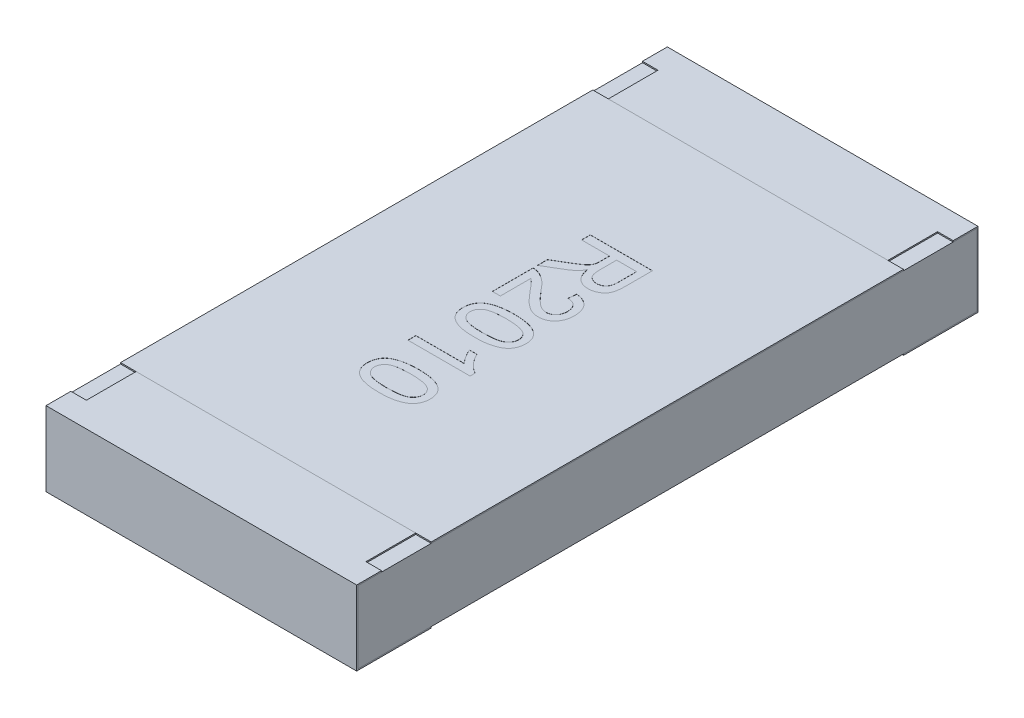
from build123d import *

# Parameters (mm, degrees)
BOSS_EXTRUDE2_DEPTH   = 1.25
BOSS_EXTRUDE2_2_DEPTH = 1.25
BOSS_EXTRUDE3_START   = -1.25
SKETCH5_W             = 4.98
SKETCH5_H             = 0.58
BOSS_EXTRUDE3_DEPTH   = 2.5
SKETCH6_W             = 0.125
SKETCH6_H             = 0.4
CUT_EXTRUDE1_DEPTH    = 0.01
SKETCH7_W             = 2.5
SKETCH7_H             = 3.8
BOSS_EXTRUDE4_DEPTH   = 0.01
TEXT2010_DEPTH        = 0.001


with BuildPart() as part:
    # Sketch4 → Boss-Extrude2 (new body, symmetric)
    with BuildSketch(Plane(origin=(0, 0, 0), x_dir=(0, 0, -1), z_dir=(1, 0, 0))):
        Polygon((-2.5, 0.3), (-2.5, -0.3), (-1.9, -0.3), (-1.9, -0.29), (-2.49, -0.29), (-2.49, 0.29), (-1.9, 0.29), (-1.9, 0.3), align=None)
    extrude(amount=BOSS_EXTRUDE2_DEPTH, both=True)


with BuildPart() as body_2:
    # Sketch4 → Boss-Extrude2 2 (new body, symmetric)
    with BuildSketch(Plane(origin=(0, 0, 0), x_dir=(0, 0, -1), z_dir=(1, 0, 0))):
        Polygon((1.9, 0.3), (2.5, 0.3), (2.5, -0.3), (1.9, -0.3), (1.9, -0.29), (2.49, -0.29), (2.49, 0.29), (1.9, 0.29), align=None)
    extrude(amount=BOSS_EXTRUDE2_2_DEPTH, both=True)


with BuildPart() as body_3:
    # Sketch5 → Boss-Extrude3 (new body)
    with BuildSketch(Plane(origin=(0, 0, 0), x_dir=(0, 0, -1), z_dir=(1, 0, 0)).offset(BOSS_EXTRUDE3_START)):
        Rectangle(SKETCH5_W, SKETCH5_H)
    extrude(amount=BOSS_EXTRUDE3_DEPTH)


with BuildPart() as cut_extrude1_tool:
    # Sketch6 → Cut-Extrude1 (new body)
    with BuildSketch(Plane(origin=(0, 0.3, 0), x_dir=(1, 0, 0), z_dir=(0, 1, 0))):
        with Locations((-1.1875, 2.1)):
            Rectangle(SKETCH6_W, SKETCH6_H)
        with Locations((1.1875, 2.1)):
            Rectangle(SKETCH6_W, SKETCH6_H)
        with Locations((1.1875, -2.1)):
            Rectangle(SKETCH6_W, SKETCH6_H)
        with Locations((-1.1875, -2.1)):
            Rectangle(SKETCH6_W, SKETCH6_H)
    extrude(amount=-CUT_EXTRUDE1_DEPTH)


with BuildPart() as part_1:
    add(part.part)

    # Cut-Extrude1: cut by cut_extrude1_tool
    add(cut_extrude1_tool.part, mode=Mode.SUBTRACT)


with BuildPart() as body_2_1:
    add(body_2.part)

    # Cut-Extrude1: cut by cut_extrude1_tool
    add(cut_extrude1_tool.part, mode=Mode.SUBTRACT)


with BuildPart() as body_4:
    # Sketch7 → Boss-Extrude4 (new body)
    with BuildSketch(Plane(origin=(0, 0.29, 0), x_dir=(1, 0, 0), z_dir=(0, 1, 0))):
        Rectangle(SKETCH7_W, SKETCH7_H)
    extrude(amount=BOSS_EXTRUDE4_DEPTH)

    # Sketch15 → TEXT2010 (cut)
    with BuildSketch(Plane(origin=(0, 0.3, 0), x_dir=(1, 0, 0), z_dir=(0, 1, 0))):
        with BuildLine():
            Line((-0.25, 0.880488889), (0.25, 0.880488889))
            Line((0.25, 0.880488889), (0.25, 0.663541774))
            add(Edge.make_bspline(
                [(0.25, 0.663541774), (0.249960163, 0.658433309), (0.249883063, 0.648546474), (0.249332125, 0.634208918), (0.248161656, 0.620857867), (0.246854386, 0.608409178), (0.244924176, 0.596884152), (0.242659692, 0.586277296), (0.239983333, 0.576629293), (0.236819773, 0.56786672), (0.233241826, 0.559736335), (0.228824875, 0.552202105), (0.223992823, 0.544941118), (0.218269952, 0.538240611), (0.212116317, 0.531807283), (0.205227709, 0.525860975), (0.197701412, 0.520372665), (0.18694151, 0.513600582), (0.17253828, 0.506474807), (0.154200832, 0.500392976), (0.134978762, 0.496504557), (0.121846978, 0.496085912), (0.115184295, 0.495873504)],
                knots=[0, 0, 0, 0, 1.5326e-05, 2.9661e-05, 4.3028e-05, 5.5527e-05, 6.7202e-05, 7.8066e-05, 8.8054e-05, 9.721e-05, 0.000105997, 0.000114656, 0.000123379, 0.000132125, 0.00014105, 0.000150068, 0.000159383, 0.00016897, 0.000188187, 0.000207412, 0.0002268, 0.000246768, 0.000246768, 0.000246768, 0.000246768], degree=3))
            add(Edge.make_bspline(
                [(0.115184295, 0.495873504), (0.110907215, 0.495971346), (0.10245969, 0.496164591), (0.090039553, 0.497644844), (0.078172662, 0.500323298), (0.066754852, 0.503757703), (0.055948764, 0.508459046), (0.045530439, 0.513902893), (0.035798164, 0.520656429), (0.026427897, 0.5281976), (0.017837878, 0.536964729), (0.00991265, 0.546723949), (0.003065461, 0.557720878), (-0.003087965, 0.569753154), (-0.008472636, 0.582842612), (-0.013000013, 0.597076292), (-0.016544481, 0.612403796), (-0.01831997, 0.623033042), (-0.019230769, 0.628485684)],
                knots=[0, 0, 0, 0, 1.283e-05, 2.5341e-05, 3.7443e-05, 4.9292e-05, 6.1049e-05, 7.2745e-05, 8.4496e-05, 9.6525e-05, 0.000108778, 0.000121245, 0.000134166, 0.00014756, 0.000161752, 0.000176576, 0.00019232, 0.000208902, 0.000208902, 0.000208902, 0.000208902], degree=3))
            add(Edge.make_bspline(
                [(-0.019230769, 0.628485684), (-0.021256287, 0.624455315), (-0.025089867, 0.616827269), (-0.03124439, 0.606305694), (-0.037334993, 0.597270614), (-0.041788652, 0.592059201), (-0.043870192, 0.589623504)],
                knots=[0, 0, 0, 0, 1.3529e-05, 2.5605e-05, 3.6551e-05, 4.6157e-05, 4.6157e-05, 4.6157e-05, 4.6157e-05], degree=3))
            add(Edge.make_bspline(
                [(-0.043870192, 0.589623504), (-0.048494022, 0.584892173), (-0.057976735, 0.575188991), (-0.074278364, 0.561947731), (-0.09220549, 0.548845663), (-0.105269317, 0.540979455), (-0.111979167, 0.536939209)],
                knots=[0, 0, 0, 0, 1.9831e-05, 4.0671e-05, 6.291e-05, 8.6395e-05, 8.6395e-05, 8.6395e-05, 8.6395e-05], degree=3))
            Line((-0.111979167, 0.536939209), (-0.25, 0.454907959))
            Line((-0.25, 0.454907959), (-0.25, 0.535737286))
            Line((-0.25, 0.535737286), (-0.14443109, 0.598036966))
            add(Edge.make_bspline(
                [(-0.14443109, 0.598036966), (-0.14072714, 0.600277042), (-0.133549493, 0.604617941), (-0.123065864, 0.610886704), (-0.113417718, 0.617038577), (-0.104312641, 0.622725698), (-0.095987375, 0.628252275), (-0.088193556, 0.633307958), (-0.081239279, 0.638281723), (-0.072863649, 0.644066276), (-0.063747422, 0.651040393), (-0.054441051, 0.659233793), (-0.046842147, 0.666836377), (-0.039501217, 0.676348247), (-0.032660963, 0.688151184), (-0.029482057, 0.698163079), (-0.027944712, 0.703004915)],
                knots=[0, 0, 0, 0, 1.2986e-05, 2.5165e-05, 3.6642e-05, 4.7312e-05, 5.7369e-05, 6.6619e-05, 7.5178e-05, 8.3014e-05, 9.7157e-05, 0.000109576, 0.000120201, 0.000129337, 0.000145574, 0.000160781, 0.000160781, 0.000160781, 0.000160781], degree=3))
            add(Edge.make_bspline(
                [(-0.027944712, 0.703004915), (-0.027578209, 0.705037271), (-0.026741472, 0.7096772), (-0.026194997, 0.717555789), (-0.025614988, 0.727101666), (-0.025631888, 0.734019726), (-0.025641026, 0.737760524)],
                knots=[0, 0, 0, 0, 6.191e-06, 1.4135e-05, 2.3663e-05, 3.4882e-05, 3.4882e-05, 3.4882e-05, 3.4882e-05], degree=3))
            Line((-0.025641026, 0.737760524), (-0.025641026, 0.809976068))
            Line((-0.025641026, 0.809976068), (-0.25, 0.809976068))
            Line((-0.25, 0.809976068), (-0.25, 0.880488889))
        make_face()
        with BuildLine():
            Line((0.032051282, 0.809976068), (0.032051282, 0.676061806))
            add(Edge.make_bspline(
                [(0.032051282, 0.676061806), (0.032156765, 0.669346925), (0.032353956, 0.656794087), (0.034025946, 0.639239632), (0.036712066, 0.624252137), (0.0405672, 0.611551859), (0.045943674, 0.600887524), (0.052623746, 0.591725856), (0.060751598, 0.583931851), (0.07009756, 0.577562003), (0.080294979, 0.572544951), (0.091082454, 0.569120007), (0.102226625, 0.56673387), (0.10982965, 0.566503199), (0.113681891, 0.566386325)],
                knots=[0, 0, 0, 0, 2.0141e-05, 3.7652e-05, 5.2837e-05, 6.5761e-05, 7.7318e-05, 8.8497e-05, 9.9618e-05, 0.000110925, 0.000122303, 0.000133579, 0.000144815, 0.000156355, 0.000156355, 0.000156355, 0.000156355], degree=3))
            add(Edge.make_bspline(
                [(0.113681891, 0.566386325), (0.116488464, 0.566479389), (0.121985715, 0.566661673), (0.130054155, 0.567617268), (0.137721037, 0.569475173), (0.14502689, 0.571928531), (0.151918204, 0.575206716), (0.158448379, 0.579101065), (0.164581222, 0.583748226), (0.170335414, 0.589071281), (0.175571167, 0.595183117), (0.180088486, 0.602164269), (0.183927233, 0.609959679), (0.186973919, 0.618578408), (0.189410772, 0.627993304), (0.191031932, 0.638257965), (0.192204997, 0.649325448), (0.192272821, 0.656994573), (0.192307692, 0.660937607)],
                knots=[0, 0, 0, 0, 8.423e-06, 1.6498e-05, 2.4321e-05, 3.205e-05, 3.9577e-05, 4.7169e-05, 5.4822e-05, 6.2617e-05, 7.0646e-05, 7.8897e-05, 8.7497e-05, 9.6653e-05, 0.000106273, 0.000116631, 0.000127803, 0.000139626, 0.000139626, 0.000139626, 0.000139626], degree=3))
            Line((0.192307692, 0.660937607), (0.192307692, 0.809976068))
            Line((0.192307692, 0.809976068), (0.032051282, 0.809976068))
        make_face(mode=Mode.SUBTRACT)
        with BuildLine():
            Line((-0.185897436, 0.09202735), (-0.25, 0.09202735))
            Line((-0.25, 0.09202735), (-0.25, 0.418950427))
            add(Edge.make_bspline(
                [(-0.25, 0.418950427), (-0.246190204, 0.41895712), (-0.238583383, 0.418970484), (-0.227333376, 0.417683287), (-0.21623261, 0.415667279), (-0.209114131, 0.41338778), (-0.205528846, 0.41223969)],
                knots=[0, 0, 0, 0, 1.142e-05, 2.2802e-05, 3.392e-05, 4.5202e-05, 4.5202e-05, 4.5202e-05, 4.5202e-05], degree=3))
            add(Edge.make_bspline(
                [(-0.205528846, 0.41223969), (-0.199672194, 0.410116329), (-0.187747085, 0.405792817), (-0.170501435, 0.397066827), (-0.153461868, 0.386632593), (-0.139489569, 0.376646806), (-0.128408004, 0.367449883), (-0.11963342, 0.359865787), (-0.110764129, 0.351322457), (-0.101641984, 0.341975633), (-0.092266458, 0.331882039), (-0.082593861, 0.321042069), (-0.07280804, 0.309323603), (-0.066321448, 0.301143058), (-0.063000801, 0.296955235)],
                knots=[0, 0, 0, 0, 1.8675e-05, 3.8026e-05, 5.7849e-05, 7.8586e-05, 8.9474e-05, 0.000101045, 0.000113371, 0.000126404, 0.000140223, 0.000154696, 0.000169983, 0.000186016, 0.000186016, 0.000186016, 0.000186016], degree=3))
            add(Edge.make_bspline(
                [(-0.063000801, 0.296955235), (-0.057585784, 0.290521682), (-0.047158825, 0.278133468), (-0.031686185, 0.260639368), (-0.017318962, 0.244661355), (-0.003805341, 0.230453862), (0.008723604, 0.217900685), (0.020239487, 0.206972349), (0.03070637, 0.197574824), (0.040503108, 0.189822835), (0.049753955, 0.183282244), (0.058777584, 0.177739671), (0.06773162, 0.173120672), (0.076587728, 0.169273663), (0.085383783, 0.166231007), (0.094145409, 0.164157003), (0.102785672, 0.162750486), (0.108534999, 0.162609763), (0.111378205, 0.162540171)],
                knots=[0, 0, 0, 0, 2.5226e-05, 4.8575e-05, 7.0061e-05, 8.9685e-05, 0.000107391, 0.000123262, 0.00013731, 0.000149574, 0.000160717, 0.000171282, 0.000181316, 0.000190917, 0.000200229, 0.000209193, 0.000217905, 0.000226428, 0.000226428, 0.000226428, 0.000226428], degree=3))
            add(Edge.make_bspline(
                [(0.111378205, 0.162540171), (0.114188238, 0.162609771), (0.119701369, 0.162746322), (0.127769802, 0.164041916), (0.135539896, 0.165845486), (0.14287177, 0.16876131), (0.149982559, 0.172232015), (0.156647535, 0.176684045), (0.163032944, 0.181834084), (0.168969907, 0.187730611), (0.17454131, 0.194170361), (0.179166687, 0.201368281), (0.183368098, 0.208867469), (0.186646742, 0.216915779), (0.189173495, 0.225441527), (0.190933763, 0.234431042), (0.192071797, 0.243908323), (0.192227868, 0.250377362), (0.192307692, 0.253686004)],
                knots=[0, 0, 0, 0, 8.423e-06, 1.6525e-05, 2.4469e-05, 3.23e-05, 4.0139e-05, 4.8167e-05, 5.6286e-05, 6.4714e-05, 7.3243e-05, 8.1771e-05, 9.0332e-05, 9.9e-05, 0.000107778, 0.000116971, 0.00012645, 0.000136374, 0.000136374, 0.000136374, 0.000136374], degree=3))
            add(Edge.make_bspline(
                [(0.192307692, 0.253686004), (0.192227732, 0.257161444), (0.192071243, 0.263963134), (0.190936175, 0.27390646), (0.189191722, 0.283341883), (0.186569692, 0.292235752), (0.183136978, 0.300570279), (0.179045534, 0.30840455), (0.174196706, 0.315708608), (0.168565002, 0.32236557), (0.162430447, 0.328531988), (0.155494268, 0.333741256), (0.148121475, 0.338294869), (0.140077995, 0.341887091), (0.131540513, 0.344816661), (0.122382293, 0.346931237), (0.11264261, 0.348086949), (0.105972365, 0.348319024), (0.102564103, 0.348437607)],
                knots=[0, 0, 0, 0, 1.0424e-05, 2.0401e-05, 2.9987e-05, 3.9178e-05, 4.8162e-05, 5.6988e-05, 6.5655e-05, 7.4401e-05, 8.3113e-05, 9.1687e-05, 0.000100362, 0.000109057, 0.000118053, 0.000127407, 0.000137196, 0.000147425, 0.000147425, 0.000147425, 0.000147425], degree=3))
            Line((0.102564103, 0.348437607), (0.108974359, 0.412540171))
            add(Edge.make_bspline(
                [(0.108974359, 0.412540171), (0.114561103, 0.41188438), (0.125429633, 0.410608594), (0.141170053, 0.407429502), (0.15581619, 0.402971053), (0.169558239, 0.397620202), (0.182228095, 0.390961265), (0.193871977, 0.383241502), (0.20454309, 0.374466932), (0.213993267, 0.364484755), (0.222618938, 0.353677034), (0.229876147, 0.341775668), (0.236164414, 0.329056751), (0.241249058, 0.31542976), (0.245145041, 0.300900044), (0.247930691, 0.285490232), (0.249649875, 0.269182881), (0.249881626, 0.257997175), (0.25, 0.252283761)],
                knots=[0, 0, 0, 0, 1.6871e-05, 3.2822e-05, 4.8095e-05, 6.2751e-05, 7.6998e-05, 9.0943e-05, 0.000104601, 0.000118344, 0.000132109, 0.000146007, 0.000160072, 0.00017462, 0.000189563, 0.000205142, 0.000221557, 0.000238695, 0.000238695, 0.000238695, 0.000238695], degree=3))
            add(Edge.make_bspline(
                [(0.25, 0.252283761), (0.24990096, 0.246502004), (0.249708029, 0.235239108), (0.247735103, 0.218826956), (0.244659885, 0.203342769), (0.240382222, 0.188724571), (0.234732773, 0.175050027), (0.227928529, 0.16227232), (0.219852523, 0.150431907), (0.210540088, 0.13968953), (0.200369372, 0.130002166), (0.189509921, 0.121525077), (0.178049555, 0.114398287), (0.166021375, 0.108503455), (0.153347568, 0.103989727), (0.140075652, 0.10084848), (0.126237909, 0.098704231), (0.116795268, 0.098527663), (0.111979167, 0.098437607)],
                knots=[0, 0, 0, 0, 1.7338e-05, 3.3775e-05, 4.9509e-05, 6.4657e-05, 7.9389e-05, 9.3818e-05, 0.000108014, 0.000122289, 0.000136388, 0.000150092, 0.000163543, 0.000176803, 0.000190204, 0.000203808, 0.000217675, 0.000232111, 0.000232111, 0.000232111, 0.000232111], degree=3))
            add(Edge.make_bspline(
                [(0.111979167, 0.098437607), (0.107030663, 0.098572796), (0.097122734, 0.098843473), (0.082332055, 0.101035598), (0.067657262, 0.104564257), (0.052981733, 0.109460541), (0.038292684, 0.116274616), (0.023237391, 0.12466669), (0.007927337, 0.135155642), (-0.005185376, 0.145102726), (-0.016100688, 0.154468166), (-0.025104319, 0.162769505), (-0.034707985, 0.172371302), (-0.045099702, 0.183018221), (-0.056125829, 0.19492833), (-0.067952516, 0.207884594), (-0.080329296, 0.222144349), (-0.088782578, 0.232045315), (-0.093149038, 0.237159562)],
                knots=[0, 0, 0, 0, 1.484e-05, 2.9713e-05, 4.4751e-05, 6.0081e-05, 7.6038e-05, 9.3257e-05, 0.000111731, 0.000131664, 0.000142604, 0.000154866, 0.000168394, 0.000183339, 0.000199497, 0.000217082, 0.000235964, 0.000256139, 0.000256139, 0.000256139, 0.000256139], degree=3))
            add(Edge.make_bspline(
                [(-0.093149038, 0.237159562), (-0.096714295, 0.241539058), (-0.103512691, 0.249890082), (-0.113369606, 0.261770081), (-0.122404327, 0.272414232), (-0.1303383, 0.28205729), (-0.137487823, 0.290372521), (-0.143708014, 0.297538273), (-0.149086369, 0.303483393), (-0.157337473, 0.312546424), (-0.169000351, 0.324112538), (-0.180421993, 0.332566118), (-0.185897436, 0.336618697)],
                knots=[0, 0, 0, 0, 1.6942e-05, 3.2305e-05, 4.6309e-05, 5.8826e-05, 6.9766e-05, 7.9207e-05, 8.7292e-05, 9.3814e-05, 0.000115985, 0.0001364, 0.0001364, 0.0001364, 0.0001364], degree=3))
            Line((-0.185897436, 0.336618697), (-0.185897436, 0.09202735))
        make_face()
        with BuildLine():
            add(Edge.make_bspline(
                [(-0.003405449, 0.02151453), (0.00374001, 0.021449947), (0.017734955, 0.021323455), (0.038212074, 0.020538869), (0.057658345, 0.019169043), (0.076056886, 0.017124281), (0.093449201, 0.014702864), (0.10981056, 0.011555131), (0.125177356, 0.008013062), (0.139534663, 0.003764656), (0.153002146, -0.000907837), (0.165571338, -0.006191765), (0.17716789, -0.01218915), (0.188106731, -0.018359184), (0.197875457, -0.025542681), (0.207092817, -0.032827612), (0.215232666, -0.040959046), (0.222561437, -0.049550247), (0.229026612, -0.058743597), (0.234605809, -0.068486295), (0.239531692, -0.078741958), (0.24323993, -0.089705748), (0.246262921, -0.101150141), (0.248486672, -0.113163207), (0.249797647, -0.125758191), (0.249931787, -0.134365091), (0.25, -0.13874188)],
                knots=[0, 0, 0, 0, 2.1436e-05, 4.1985e-05, 6.1467e-05, 7.9905e-05, 9.7512e-05, 0.000114131, 0.000129874, 0.000144802, 0.000159025, 0.000172624, 0.000185659, 0.000198182, 0.000210244, 0.000221992, 0.000233395, 0.000244694, 0.000255837, 0.000267055, 0.000278346, 0.000289908, 0.000301715, 0.000313836, 0.000326523, 0.00033965, 0.00033965, 0.00033965, 0.00033965], degree=3))
            add(Edge.make_bspline(
                [(0.25, -0.13874188), (0.249811049, -0.145163084), (0.249439847, -0.157777797), (0.24641749, -0.176197302), (0.241234494, -0.193549042), (0.234296981, -0.209830301), (0.22532276, -0.22468903), (0.214693842, -0.238122704), (0.201965218, -0.249588542), (0.1875546, -0.259465293), (0.17143338, -0.267934605), (0.153753376, -0.275510753), (0.134439642, -0.282303475), (0.117200119, -0.287275452), (0.102293144, -0.290761248), (0.089975045, -0.292883499), (0.076724552, -0.294842951), (0.062509934, -0.296231837), (0.047397625, -0.297645142), (0.03132173, -0.298342908), (0.014293165, -0.298875407), (0.002604687, -0.298956561), (-0.003405449, -0.298998291)],
                knots=[0, 0, 0, 0, 1.9257e-05, 3.7831e-05, 5.58e-05, 7.3476e-05, 9.0773e-05, 0.00010773, 0.000124675, 0.000141956, 0.000160014, 0.000179215, 0.000199617, 0.000221396, 0.00023301, 0.000245525, 0.000258882, 0.000273184, 0.000288364, 0.00030441, 0.000321445, 0.000339474, 0.000339474, 0.000339474, 0.000339474], degree=3))
            add(Edge.make_bspline(
                [(-0.003405449, -0.298998291), (-0.010517401, -0.298932862), (-0.024411998, -0.298805033), (-0.044724145, -0.298036412), (-0.06402645, -0.296601853), (-0.082342451, -0.294753213), (-0.099689135, -0.292264254), (-0.116024046, -0.289153341), (-0.131367222, -0.285560232), (-0.145734136, -0.281494137), (-0.159144561, -0.276763531), (-0.171662676, -0.271428032), (-0.183411141, -0.265706802), (-0.194171149, -0.259217372), (-0.20412082, -0.252305743), (-0.213291478, -0.244907343), (-0.221552781, -0.236868927), (-0.228857474, -0.228197534), (-0.23543891, -0.219069811), (-0.241068837, -0.209301795), (-0.245765609, -0.198916338), (-0.249691119, -0.188005999), (-0.252674425, -0.176498361), (-0.25488945, -0.164453385), (-0.256212459, -0.151792488), (-0.256343414, -0.143152103), (-0.256410256, -0.13874188)],
                knots=[0, 0, 0, 0, 2.1336e-05, 4.1685e-05, 6.0966e-05, 7.9394e-05, 9.6902e-05, 0.000113521, 0.000129264, 0.000144164, 0.000158292, 0.000171891, 0.000184971, 0.000197459, 0.000209546, 0.000221293, 0.000232768, 0.000244066, 0.000255267, 0.000266486, 0.000277825, 0.000289421, 0.000301228, 0.000313447, 0.000326134, 0.000339362, 0.000339362, 0.000339362, 0.000339362], degree=3))
            add(Edge.make_bspline(
                [(-0.256410256, -0.13874188), (-0.256245319, -0.132959697), (-0.255923737, -0.121686032), (-0.253738786, -0.105221675), (-0.24989317, -0.089768997), (-0.244735657, -0.075197665), (-0.237837185, -0.061671464), (-0.229443847, -0.049125812), (-0.219750923, -0.037308613), (-0.212103429, -0.030505914), (-0.208233173, -0.027063194)],
                knots=[0, 0, 0, 0, 1.7346e-05, 3.382e-05, 4.9708e-05, 6.5042e-05, 8.0093e-05, 9.5122e-05, 0.000110267, 0.000125786, 0.000125786, 0.000125786, 0.000125786], degree=3))
            add(Edge.make_bspline(
                [(-0.208233173, -0.027063194), (-0.202516992, -0.023100544), (-0.190729983, -0.01492939), (-0.170632038, -0.005365763), (-0.148507023, 0.003165162), (-0.123920847, 0.009860373), (-0.097069189, 0.015104393), (-0.067899359, 0.018891885), (-0.036423961, 0.021035232), (-0.014660077, 0.021351157), (-0.003405449, 0.02151453)],
                knots=[0, 0, 0, 0, 2.0835e-05, 4.2963e-05, 6.655e-05, 9.192e-05, 0.000119283, 0.000148578, 0.000180105, 0.000213869, 0.000213869, 0.000213869, 0.000213869], degree=3))
        make_face()
        with BuildLine():
            add(Edge.make_bspline(
                [(-0.003205128, -0.042588034), (-0.012821947, -0.042651683), (-0.031230665, -0.042773521), (-0.057530694, -0.04404643), (-0.081256911, -0.04623769), (-0.102376465, -0.04913468), (-0.120917923, -0.052959879), (-0.136834037, -0.057762869), (-0.150315835, -0.063176982), (-0.161196223, -0.069876843), (-0.170065326, -0.077212451), (-0.177693041, -0.084785965), (-0.184176425, -0.092775564), (-0.189582244, -0.101129116), (-0.193675176, -0.109976232), (-0.196641741, -0.119220172), (-0.198348954, -0.128862946), (-0.198594249, -0.135430114), (-0.198717949, -0.13874188)],
                knots=[0, 0, 0, 0, 2.8849e-05, 5.5223e-05, 7.8964e-05, 0.00010031, 0.000119149, 0.000135688, 0.000150142, 0.000162596, 0.000173844, 0.000184609, 0.000194793, 0.000204656, 0.00021438, 0.000223946, 0.000233711, 0.000243645, 0.000243645, 0.000243645, 0.000243645], degree=3))
            add(Edge.make_bspline(
                [(-0.198717949, -0.13874188), (-0.198591546, -0.142052818), (-0.198340892, -0.14861834), (-0.196671325, -0.158283395), (-0.193552042, -0.167491369), (-0.189473567, -0.176325294), (-0.184190962, -0.184739563), (-0.177683089, -0.192689922), (-0.170059903, -0.200303332), (-0.161087713, -0.207605988), (-0.150157022, -0.214254806), (-0.136686205, -0.21977048), (-0.120742218, -0.224498619), (-0.102210206, -0.228344808), (-0.081124045, -0.231253748), (-0.057463634, -0.23343176), (-0.031197443, -0.234713187), (-0.01282199, -0.234833015), (-0.003205128, -0.234895726)],
                knots=[0, 0, 0, 0, 9.934e-06, 1.9699e-05, 2.9296e-05, 3.902e-05, 4.883e-05, 5.9013e-05, 6.9779e-05, 8.1104e-05, 9.3644e-05, 0.000108005, 0.000124641, 0.00014348, 0.000164727, 0.000188467, 0.000214741, 0.00024359, 0.00024359, 0.00024359, 0.00024359], degree=3))
            add(Edge.make_bspline(
                [(-0.003205128, -0.234895726), (0.006211639, -0.234835023), (0.024253808, -0.234718718), (0.050047157, -0.23340423), (0.073375172, -0.231344359), (0.094259177, -0.228526631), (0.112677079, -0.224782347), (0.128666278, -0.220239601), (0.142198253, -0.21483065), (0.1533917, -0.208385845), (0.16263152, -0.201240053), (0.170473418, -0.193647831), (0.177345535, -0.185756107), (0.182726545, -0.177113899), (0.187139749, -0.168088602), (0.190094092, -0.158486742), (0.191990166, -0.1484323), (0.192200302, -0.141555268), (0.192307692, -0.138040759)],
                knots=[0, 0, 0, 0, 2.8248e-05, 5.4122e-05, 7.7454e-05, 9.8489e-05, 0.000117308, 0.00013379, 0.000148298, 0.000160908, 0.000172407, 0.000183245, 0.00019362, 0.000203707, 0.000213697, 0.000223676, 0.000233754, 0.000244288, 0.000244288, 0.000244288, 0.000244288], degree=3))
            add(Edge.make_bspline(
                [(0.192307692, -0.138040759), (0.192220777, -0.1347292), (0.192049391, -0.128199231), (0.190413514, -0.1186385), (0.187677963, -0.109577909), (0.183972394, -0.10091365), (0.17898543, -0.092862024), (0.173162795, -0.085103722), (0.166068563, -0.078002114), (0.160765027, -0.073722747), (0.158052885, -0.071534348)],
                knots=[0, 0, 0, 0, 9.929e-06, 1.9578e-05, 2.8989e-05, 3.8274e-05, 4.7756e-05, 5.7332e-05, 6.7318e-05, 7.777e-05, 7.777e-05, 7.777e-05, 7.777e-05], degree=3))
            add(Edge.make_bspline(
                [(0.158052885, -0.071534348), (0.154069588, -0.06915185), (0.145657703, -0.064120515), (0.131037502, -0.058490743), (0.114329394, -0.053517626), (0.095276314, -0.049423102), (0.073910945, -0.046461), (0.0502581, -0.044122536), (0.024284756, -0.042907791), (0.006210985, -0.04269756), (-0.003205128, -0.042588034)],
                knots=[0, 0, 0, 0, 1.3902e-05, 2.9358e-05, 4.6819e-05, 6.6189e-05, 8.7748e-05, 0.000111498, 0.000137472, 0.000165722, 0.000165722, 0.000165722, 0.000165722], degree=3))
        make_face(mode=Mode.SUBTRACT)
        with BuildLine():
            Line((-0.25, -0.587459829), (-0.25, -0.523357265))
            Line((-0.25, -0.523357265), (0.139623397, -0.523357265))
            add(Edge.make_bspline(
                [(0.139623397, -0.523357265), (0.136064182, -0.519666022), (0.128666742, -0.511994178), (0.118190939, -0.499030077), (0.107619408, -0.484563656), (0.097315673, -0.4688349), (0.08780582, -0.452678336), (0.079128194, -0.437112396), (0.071822591, -0.422354494), (0.067824115, -0.412636042), (0.065905449, -0.40797265)],
                knots=[0, 0, 0, 0, 1.5377e-05, 3.1959e-05, 4.9949e-05, 6.9117e-05, 8.8339e-05, 0.000106181, 0.000122576, 0.0001377, 0.0001377, 0.0001377, 0.0001377], degree=3))
            Line((0.065905449, -0.40797265), (0.125, -0.40797265))
            add(Edge.make_bspline(
                [(0.125, -0.40797265), (0.129125269, -0.41598285), (0.137255931, -0.431770481), (0.151298701, -0.454074989), (0.166521642, -0.474898647), (0.182921383, -0.49389674), (0.199684862, -0.51092732), (0.216599871, -0.525279238), (0.233046379, -0.537288009), (0.244515995, -0.543313037), (0.25, -0.546193803)],
                knots=[0, 0, 0, 0, 2.702e-05, 5.3254e-05, 7.8977e-05, 0.000104333, 0.000128484, 0.000150581, 0.000170841, 0.000189403, 0.000189403, 0.000189403, 0.000189403], degree=3))
            Line((0.25, -0.546193803), (0.25, -0.587459829))
            Line((0.25, -0.587459829), (-0.25, -0.587459829))
        make_face()
        with BuildLine():
            add(Edge.make_bspline(
                [(-0.003405449, -0.747716239), (0.00374001, -0.747780823), (0.017734955, -0.747907314), (0.038212074, -0.7486919), (0.057658345, -0.750061726), (0.076056886, -0.752106488), (0.093449201, -0.754527905), (0.10981056, -0.757675639), (0.125177356, -0.761217707), (0.139534663, -0.765466113), (0.153002146, -0.770138606), (0.165571338, -0.775422534), (0.17716789, -0.781419919), (0.188106731, -0.787589953), (0.197875457, -0.794773451), (0.207092817, -0.802058381), (0.215232666, -0.810189815), (0.222561437, -0.818781016), (0.229026612, -0.827974367), (0.234605809, -0.837717064), (0.239531692, -0.847972727), (0.24323993, -0.858936517), (0.246262921, -0.87038091), (0.248486672, -0.882393976), (0.249797647, -0.89498896), (0.249931787, -0.90359586), (0.25, -0.90797265)],
                knots=[0, 0, 0, 0, 2.1436e-05, 4.1985e-05, 6.1467e-05, 7.9905e-05, 9.7512e-05, 0.000114131, 0.000129874, 0.000144802, 0.000159025, 0.000172624, 0.000185659, 0.000198182, 0.000210244, 0.000221992, 0.000233395, 0.000244694, 0.000255837, 0.000267055, 0.000278346, 0.000289908, 0.000301715, 0.000313836, 0.000326523, 0.00033965, 0.00033965, 0.00033965, 0.00033965], degree=3))
            add(Edge.make_bspline(
                [(0.25, -0.90797265), (0.249811049, -0.914393853), (0.249439847, -0.927008566), (0.24641749, -0.945428071), (0.241234494, -0.962779811), (0.234296981, -0.97906107), (0.22532276, -0.9939198), (0.214693842, -1.007353473), (0.201965218, -1.018819312), (0.1875546, -1.028696062), (0.17143338, -1.037165375), (0.153753376, -1.044741522), (0.134439642, -1.051534244), (0.117200119, -1.056506221), (0.102293144, -1.059992017), (0.089975045, -1.062114268), (0.076724552, -1.06407372), (0.062509934, -1.065462607), (0.047397625, -1.066875912), (0.03132173, -1.067573678), (0.014293165, -1.068106176), (0.002604687, -1.068187331), (-0.003405449, -1.06822906)],
                knots=[0, 0, 0, 0, 1.9257e-05, 3.7831e-05, 5.58e-05, 7.3476e-05, 9.0773e-05, 0.00010773, 0.000124675, 0.000141956, 0.000160014, 0.000179215, 0.000199617, 0.000221396, 0.00023301, 0.000245525, 0.000258882, 0.000273184, 0.000288364, 0.00030441, 0.000321445, 0.000339474, 0.000339474, 0.000339474, 0.000339474], degree=3))
            add(Edge.make_bspline(
                [(-0.003405449, -1.06822906), (-0.010517401, -1.068163631), (-0.024411998, -1.068035803), (-0.044724145, -1.067267181), (-0.06402645, -1.065832622), (-0.082342451, -1.063983982), (-0.099689135, -1.061495023), (-0.116024046, -1.058384111), (-0.131367222, -1.054791001), (-0.145734136, -1.050724906), (-0.159144561, -1.0459943), (-0.171662676, -1.040658802), (-0.183411141, -1.034937571), (-0.194171149, -1.028448141), (-0.20412082, -1.021536513), (-0.213291478, -1.014138112), (-0.221552781, -1.006099696), (-0.228857474, -0.997428303), (-0.23543891, -0.98830058), (-0.241068837, -0.978532564), (-0.245765609, -0.968147107), (-0.249691119, -0.957236768), (-0.252674425, -0.945729131), (-0.25488945, -0.933684154), (-0.256212459, -0.921023257), (-0.256343414, -0.912382872), (-0.256410256, -0.90797265)],
                knots=[0, 0, 0, 0, 2.1336e-05, 4.1685e-05, 6.0966e-05, 7.9394e-05, 9.6902e-05, 0.000113521, 0.000129264, 0.000144164, 0.000158292, 0.000171891, 0.000184971, 0.000197459, 0.000209546, 0.000221293, 0.000232768, 0.000244066, 0.000255267, 0.000266486, 0.000277825, 0.000289421, 0.000301228, 0.000313447, 0.000326134, 0.000339362, 0.000339362, 0.000339362, 0.000339362], degree=3))
            add(Edge.make_bspline(
                [(-0.256410256, -0.90797265), (-0.256245319, -0.902190466), (-0.255923737, -0.890916801), (-0.253738786, -0.874452444), (-0.24989317, -0.858999767), (-0.244735657, -0.844428435), (-0.237837185, -0.830902234), (-0.229443847, -0.818356581), (-0.219750923, -0.806539382), (-0.212103429, -0.799736684), (-0.208233173, -0.796293964)],
                knots=[0, 0, 0, 0, 1.7346e-05, 3.382e-05, 4.9708e-05, 6.5042e-05, 8.0093e-05, 9.5122e-05, 0.000110267, 0.000125786, 0.000125786, 0.000125786, 0.000125786], degree=3))
            add(Edge.make_bspline(
                [(-0.208233173, -0.796293964), (-0.202516992, -0.792331314), (-0.190729983, -0.78416016), (-0.170632038, -0.774596532), (-0.148507023, -0.766065608), (-0.123920847, -0.759370396), (-0.097069189, -0.754126376), (-0.067899359, -0.750338884), (-0.036423961, -0.748195537), (-0.014660077, -0.747879612), (-0.003405449, -0.747716239)],
                knots=[0, 0, 0, 0, 2.0835e-05, 4.2963e-05, 6.655e-05, 9.192e-05, 0.000119283, 0.000148578, 0.000180105, 0.000213869, 0.000213869, 0.000213869, 0.000213869], degree=3))
        make_face()
        with BuildLine():
            add(Edge.make_bspline(
                [(-0.003205128, -0.811818803), (-0.012821947, -0.811882452), (-0.031230665, -0.81200429), (-0.057530694, -0.813277199), (-0.081256911, -0.81546846), (-0.102376465, -0.818365449), (-0.120917923, -0.822190649), (-0.136834037, -0.826993639), (-0.150315835, -0.832407751), (-0.161196223, -0.839107612), (-0.170065326, -0.84644322), (-0.177693041, -0.854016734), (-0.184176425, -0.862006333), (-0.189582244, -0.870359885), (-0.193675176, -0.879207002), (-0.196641741, -0.888450941), (-0.198348954, -0.898093716), (-0.198594249, -0.904660883), (-0.198717949, -0.90797265)],
                knots=[0, 0, 0, 0, 2.8849e-05, 5.5223e-05, 7.8964e-05, 0.00010031, 0.000119149, 0.000135688, 0.000150142, 0.000162596, 0.000173844, 0.000184609, 0.000194793, 0.000204656, 0.00021438, 0.000223946, 0.000233711, 0.000243645, 0.000243645, 0.000243645, 0.000243645], degree=3))
            add(Edge.make_bspline(
                [(-0.198717949, -0.90797265), (-0.198591546, -0.911283587), (-0.198340892, -0.91784911), (-0.196671325, -0.927514164), (-0.193552042, -0.936722138), (-0.189473567, -0.945556064), (-0.184190962, -0.953970332), (-0.177683089, -0.961920691), (-0.170059903, -0.969534101), (-0.161087713, -0.976836758), (-0.150157022, -0.983485575), (-0.136686205, -0.98900125), (-0.120742218, -0.993729388), (-0.102210206, -0.997575577), (-0.081124045, -1.000484517), (-0.057463634, -1.002662529), (-0.031197443, -1.003943957), (-0.01282199, -1.004063784), (-0.003205128, -1.004126496)],
                knots=[0, 0, 0, 0, 9.934e-06, 1.9699e-05, 2.9296e-05, 3.902e-05, 4.883e-05, 5.9013e-05, 6.9779e-05, 8.1104e-05, 9.3644e-05, 0.000108005, 0.000124641, 0.00014348, 0.000164727, 0.000188467, 0.000214741, 0.00024359, 0.00024359, 0.00024359, 0.00024359], degree=3))
            add(Edge.make_bspline(
                [(-0.003205128, -1.004126496), (0.006211639, -1.004065792), (0.024253808, -1.003949487), (0.050047157, -1.002635), (0.073375172, -1.000575129), (0.094259177, -0.9977574), (0.112677079, -0.994013116), (0.128666278, -0.98947037), (0.142198253, -0.984061419), (0.1533917, -0.977616614), (0.16263152, -0.970470822), (0.170473418, -0.9628786), (0.177345535, -0.954986876), (0.182726545, -0.946344668), (0.187139749, -0.937319372), (0.190094092, -0.927717512), (0.191990166, -0.917663069), (0.192200302, -0.910786037), (0.192307692, -0.907271528)],
                knots=[0, 0, 0, 0, 2.8248e-05, 5.4122e-05, 7.7454e-05, 9.8489e-05, 0.000117308, 0.00013379, 0.000148298, 0.000160908, 0.000172407, 0.000183245, 0.00019362, 0.000203707, 0.000213697, 0.000223676, 0.000233754, 0.000244288, 0.000244288, 0.000244288, 0.000244288], degree=3))
            add(Edge.make_bspline(
                [(0.192307692, -0.907271528), (0.192220777, -0.903959969), (0.192049391, -0.89743), (0.190413514, -0.88786927), (0.187677963, -0.878808678), (0.183972394, -0.870144419), (0.17898543, -0.862092793), (0.173162795, -0.854334491), (0.166068563, -0.847232883), (0.160765027, -0.842953516), (0.158052885, -0.840765117)],
                knots=[0, 0, 0, 0, 9.929e-06, 1.9578e-05, 2.8989e-05, 3.8274e-05, 4.7756e-05, 5.7332e-05, 6.7318e-05, 7.777e-05, 7.777e-05, 7.777e-05, 7.777e-05], degree=3))
            add(Edge.make_bspline(
                [(0.158052885, -0.840765117), (0.154069588, -0.838382619), (0.145657703, -0.833351284), (0.131037502, -0.827721513), (0.114329394, -0.822748395), (0.095276314, -0.818653871), (0.073910945, -0.81569177), (0.0502581, -0.813353305), (0.024284756, -0.81213856), (0.006210985, -0.81192833), (-0.003205128, -0.811818803)],
                knots=[0, 0, 0, 0, 1.3902e-05, 2.9358e-05, 4.6819e-05, 6.6189e-05, 8.7748e-05, 0.000111498, 0.000137472, 0.000165722, 0.000165722, 0.000165722, 0.000165722], degree=3))
        make_face(mode=Mode.SUBTRACT)
    extrude(amount=-TEXT2010_DEPTH, mode=Mode.SUBTRACT)


solid = Compound([body_3.part, part_1.part, body_2_1.part, body_4.part])
